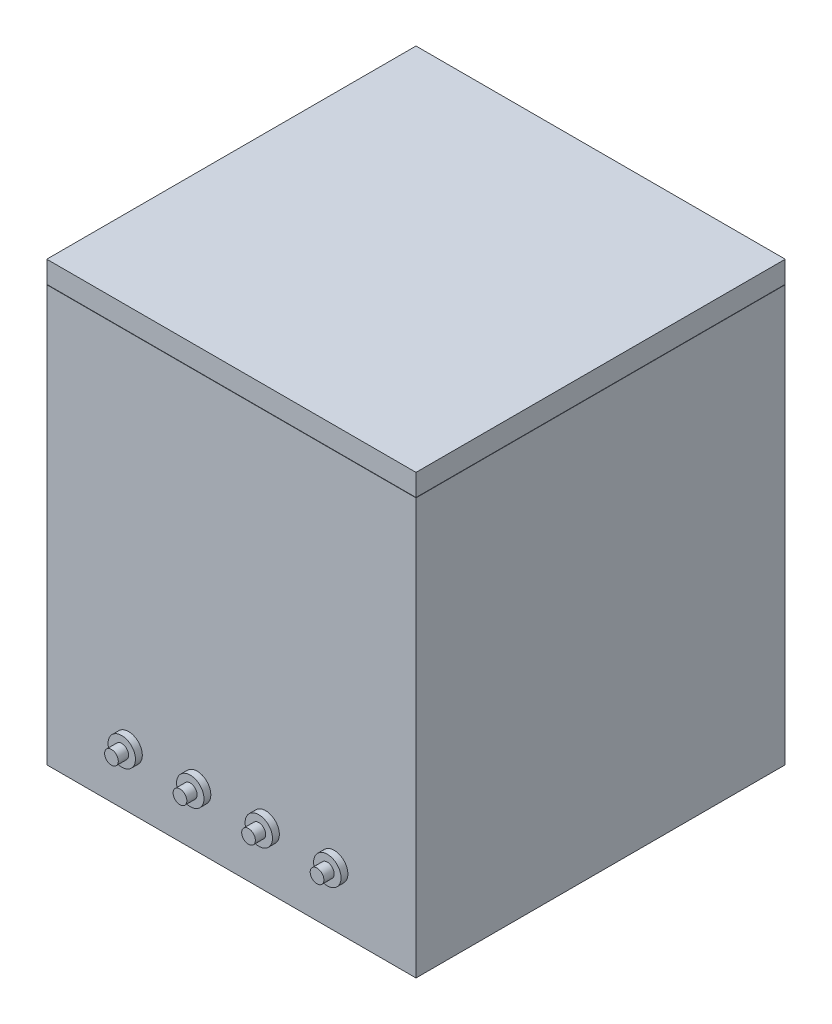
from build123d import *

# Parameters (mm, degrees)
SKETCH1_W           = 107.763073452
SKETCH1_H           = 107.763073452
SKETCH1_W_2         = 95.063073452
SKETCH1_H_2         = 95.063073452
BOSS_EXTRUDE1_DEPTH = 115
SKETCH2_W           = 107.763073452
SKETCH2_H           = 107.763073452
BOSS_EXTRUDE2_DEPTH = 6.35
SKETCH3_W           = 107.763073452
SKETCH3_H           = 107.763073452
BOSS_EXTRUDE3_DEPTH = 6.35
SKETCH4_R           = 2.5
CUT_EXTRUDE1_DEPTH  = 3.175
LPATTERN1_COUNT     = 4
LPATTERN1_PITCH     = 20


with BuildPart() as part:
    # Sketch1 → Boss-Extrude1 (new body)
    with BuildSketch(Plane(origin=(0, 0, 0), x_dir=(1, 0, 0), z_dir=(0, 1, 0))):
        Rectangle(SKETCH1_W, SKETCH1_H)
        Rectangle(SKETCH1_W_2, SKETCH1_H_2, mode=Mode.SUBTRACT)
    extrude(amount=BOSS_EXTRUDE1_DEPTH)

    # Sketch2 → Boss-Extrude2 (add)
    with BuildSketch(Plane.XZ):
        Rectangle(SKETCH2_W, SKETCH2_H)
    extrude(amount=BOSS_EXTRUDE2_DEPTH)

    # Sketch4 → Cut-Extrude1 (cut, symmetric)
    with BuildSketch(Plane.XZ.offset(6.35)):
        with Locations((-20, -25)):
            Circle(SKETCH4_R)
        with Locations((20, -25)):
            Circle(SKETCH4_R)
    extrude(amount=CUT_EXTRUDE1_DEPTH, both=True, mode=Mode.SUBTRACT)

    # Sketch6 → Revolve1 (revolve)
    with BuildSketch(Plane(origin=(0, 10, 0), x_dir=(1, 0, 0), z_dir=(0, 1, 0))):
        Polygon((-30, -53.881536726), (-30, -58.881536726), (-32, -58.881536726), (-32, -55.881536726), (-34, -55.881536726), (-34, -53.881536726), align=None)
    revolve1 = revolve(axis=Axis((-30, 10, 53.881536726), (0, 0, 1)))

    # LPattern1: Revolve1 ×4
    with Locations(*[(i * LPATTERN1_PITCH, 0, 0) for i in range(1, LPATTERN1_COUNT)]):
        add(revolve1)


with BuildPart() as body_2:
    # Sketch3 → Boss-Extrude3 (new body)
    with BuildSketch(Plane(origin=(0, 115.1, 0), x_dir=(1, 0, 0), z_dir=(0, 1, 0))):
        Rectangle(SKETCH3_W, SKETCH3_H)
    extrude(amount=BOSS_EXTRUDE3_DEPTH)


solid = Compound([part.part, body_2.part])
